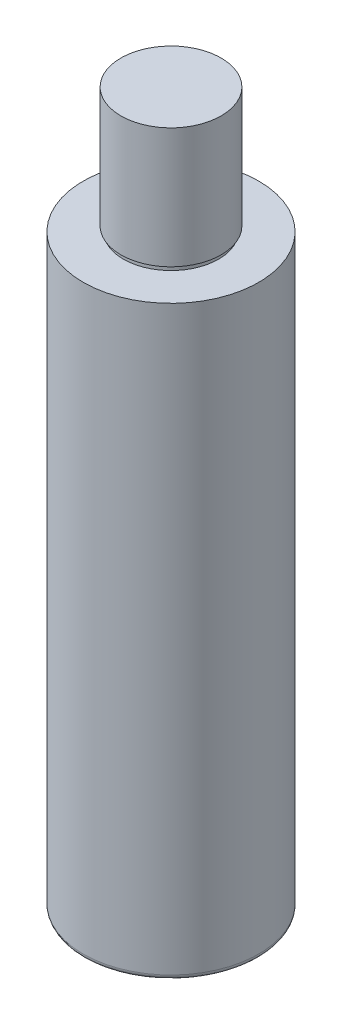
from build123d import *

# Parameters (mm, degrees)
SKETCH1_R           = 17.5
BOSS_EXTRUDE1_DEPTH = 142
SKETCH2_OUTSIDE_W   = 67.076
SKETCH2_OUTSIDE_H   = 67.076
SKETCH2_OUTSIDE_R   = 10
CUT_EXTRUDE1_DEPTH  = 25
SKETCH3_OUTSIDE_W   = 67.076
SKETCH3_OUTSIDE_H   = 67.076
SKETCH3_OUTSIDE_R   = 9.5
CUT_EXTRUDE2_DEPTH  = 1
FILLET1_R           = 1


with BuildPart() as part:
    # Sketch1 → Boss-Extrude1 (new body)
    with BuildSketch(Plane(origin=(0, 0, 0), x_dir=(1, 0, 0), z_dir=(0, 1, 0))):
        Circle(SKETCH1_R)
    extrude(amount=BOSS_EXTRUDE1_DEPTH)

    # Sketch2 outside → Cut-Extrude1 (cut)
    with BuildSketch(Plane(origin=(0, 142, 0), x_dir=(1, 0, 0), z_dir=(0, 1, 0))):
        Rectangle(SKETCH2_OUTSIDE_W, SKETCH2_OUTSIDE_H)
        Circle(SKETCH2_OUTSIDE_R, mode=Mode.SUBTRACT)
    extrude(amount=-CUT_EXTRUDE1_DEPTH, mode=Mode.SUBTRACT)

    # Sketch3 outside → Cut-Extrude2 (cut)
    with BuildSketch(Plane(origin=(0, 117, 0), x_dir=(1, 0, 0), z_dir=(0, 1, 0))):
        Rectangle(SKETCH3_OUTSIDE_W, SKETCH3_OUTSIDE_H)
        Circle(SKETCH3_OUTSIDE_R, mode=Mode.SUBTRACT)
    extrude(amount=CUT_EXTRUDE2_DEPTH, mode=Mode.SUBTRACT)

    # Fillet1
    fillet1_edges = [part.edges().sort_by_distance(p)[0] for p in [
        (-17.5, 0, 0),
    ]]
    fillet(fillet1_edges, radius=FILLET1_R)


solid = part.part
